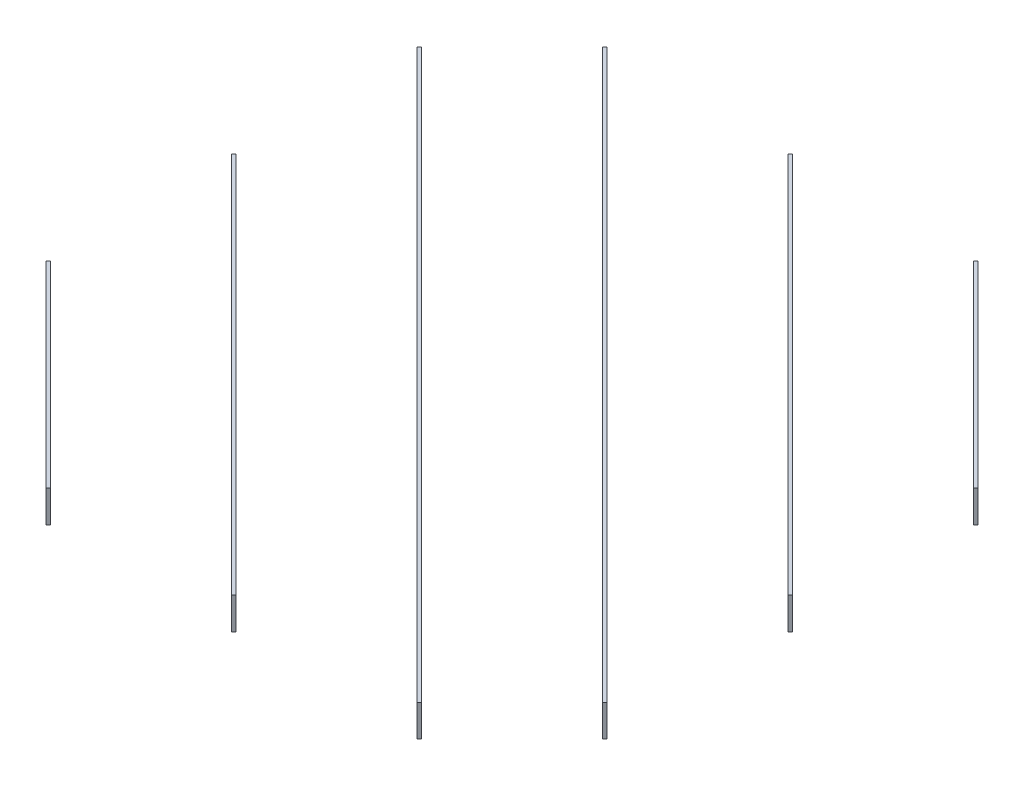
from build123d import *

# Parameters (mm, degrees)
BOSS_EXTRUDE1_DEPTH   = 60
BOSS_EXTRUDE1_2_DEPTH = 60
BOSS_EXTRUDE1_3_DEPTH = 60
BOSS_EXTRUDE1_4_DEPTH = 60
BOSS_EXTRUDE1_5_DEPTH = 60
BOSS_EXTRUDE1_6_DEPTH = 60
SKETCH3_R             = 1.5
SKETCH3_W             = 6
SKETCH3_H             = 60
CUT_EXTRUDE1_DEPTH    = 1506.601910021
SKETCH4_R             = 1.5
CUT_EXTRUDE2_DEPTH    = 1506.601910021


with BuildPart() as part:
    # Sketch2 → Boss-Extrude1 (new body)
    with BuildSketch(Plane(origin=(0, 0, 0), x_dir=(1, 0, 0), z_dir=(0, 1, 0))):
        Polygon((-625, -254.242640687), (-254.242640687, -625), (-250, -620.757359313), (-620.757359313, -250), align=None)
    extrude(amount=BOSS_EXTRUDE1_DEPTH)


with BuildPart() as body_2:
    # Sketch2 → Boss-Extrude1 2 (new body)
    with BuildSketch(Plane(origin=(0, 0, 0), x_dir=(1, 0, 0), z_dir=(0, 1, 0))):
        Polygon((-625, 95.757359313), (95.757359313, -625), (100, -620.757359313), (-620.757359313, 100), align=None)
    extrude(amount=BOSS_EXTRUDE1_2_DEPTH)


with BuildPart() as body_3:
    # Sketch2 → Boss-Extrude1 3 (new body)
    with BuildSketch(Plane(origin=(0, 0, 0), x_dir=(1, 0, 0), z_dir=(0, 1, 0))):
        Polygon((-625, 445.757359313), (445.757359313, -625), (450, -620.757359313), (-620.757359313, 450), align=None)
    extrude(amount=BOSS_EXTRUDE1_3_DEPTH)


with BuildPart() as body_4:
    # Sketch2 → Boss-Extrude1 4 (new body)
    with BuildSketch(Plane(origin=(0, 0, 0), x_dir=(1, 0, 0), z_dir=(0, 1, 0))):
        Polygon((-450, 620.757359313), (620.757359313, -450), (625, -445.757359313), (-445.757359313, 625), align=None)
    extrude(amount=BOSS_EXTRUDE1_4_DEPTH)


with BuildPart() as body_5:
    # Sketch2 → Boss-Extrude1 5 (new body)
    with BuildSketch(Plane(origin=(0, 0, 0), x_dir=(1, 0, 0), z_dir=(0, 1, 0))):
        Polygon((-100, 620.757359313), (620.757359313, -100), (625, -95.757359313), (-95.757359313, 625), align=None)
    extrude(amount=BOSS_EXTRUDE1_5_DEPTH)


with BuildPart() as body_6:
    # Sketch2 → Boss-Extrude1 6 (new body)
    with BuildSketch(Plane(origin=(0, 0, 0), x_dir=(1, 0, 0), z_dir=(0, 1, 0))):
        Polygon((250, 620.757359313), (620.757359313, 250), (625, 254.242640687), (254.242640687, 625), align=None)
    extrude(amount=BOSS_EXTRUDE1_6_DEPTH)


with BuildPart() as cut_extrude1_tool:
    # Sketch3 → Cut-Extrude1 (new body, through all)
    with BuildSketch(Plane(origin=(-439.621320344, 0, 439.621320344), x_dir=(0.707106781, 0, 0.707106781), z_dir=(-0.707106781, 0, 0.707106781))):
        with Locations((-615.718433538, 30)):
            Circle(SKETCH3_R)
        with Locations((-621.718433538, 30)):
            Circle(SKETCH3_R)
        with Locations((-618.718433538, 0)):
            Rectangle(SKETCH3_W, SKETCH3_H)
        with BuildLine():
            Line((-621.718433538, 28.5), (-621.718433538, 30))
            Line((-621.718433538, 30), (-620.218433538, 30))
            ThreePointArc((-620.218433538, 30), (-622.77909371, 31.060660172), (-621.718433538, 28.5))
        make_face()
        with BuildLine():
            Line((-620.218433538, 30), (-621.718433538, 30))
            Line((-621.718433538, 30), (-621.718433538, 28.5))
            ThreePointArc((-621.718433538, 28.5), (-620.657773366, 28.939339828), (-620.218433538, 30))
        make_face()
        with BuildLine():
            ThreePointArc((-614.218433538, 30), (-615.718433538, 31.5), (-617.218433538, 30))
            Line((-617.218433538, 30), (-615.718433538, 30))
            Line((-615.718433538, 30), (-615.718433538, 28.5))
            ThreePointArc((-615.718433538, 28.5), (-614.657773366, 28.939339828), (-614.218433538, 30))
        make_face()
        with BuildLine():
            Line((-615.718433538, 30), (-617.218433538, 30))
            ThreePointArc((-617.218433538, 30), (-616.77909371, 28.939339828), (-615.718433538, 28.5))
            Line((-615.718433538, 28.5), (-615.718433538, 30))
        make_face()
        with BuildLine():
            Line((-374.231060123, 28.5), (-374.231060123, 30))
            Line((-374.231060123, 30), (-372.731060123, 30))
            ThreePointArc((-372.731060123, 30), (-375.291720295, 31.060660172), (-374.231060123, 28.5))
        make_face()
        with BuildLine():
            Line((-372.731060123, 30), (-374.231060123, 30))
            Line((-374.231060123, 30), (-374.231060123, 28.5))
            ThreePointArc((-374.231060123, 28.5), (-373.170399951, 28.939339828), (-372.731060123, 30))
        make_face()
        with Locations((-368.231060123, 30)):
            Circle(SKETCH3_R)
        with Locations((-374.231060123, 30)):
            Circle(SKETCH3_R)
        with Locations((-371.231060123, 0)):
            Rectangle(SKETCH3_W, SKETCH3_H)
        with BuildLine():
            ThreePointArc((-366.731060123, 30), (-368.231060123, 31.5), (-369.731060123, 30))
            Line((-369.731060123, 30), (-368.231060123, 30))
            Line((-368.231060123, 30), (-368.231060123, 28.5))
            ThreePointArc((-368.231060123, 28.5), (-367.170399951, 28.939339828), (-366.731060123, 30))
        make_face()
        with BuildLine():
            Line((-368.231060123, 30), (-369.731060123, 30))
            ThreePointArc((-369.731060123, 30), (-369.291720295, 28.939339828), (-368.231060123, 28.5))
            Line((-368.231060123, 28.5), (-368.231060123, 30))
        make_face()
        with BuildLine():
            Line((-126.705577884, 28.5), (-126.705577884, 30))
            Line((-126.705577884, 30), (-125.205577884, 30))
            ThreePointArc((-125.205577884, 30), (-127.766238056, 31.060660172), (-126.705577884, 28.5))
        make_face()
        with BuildLine():
            Line((-125.205577884, 30), (-126.705577884, 30))
            Line((-126.705577884, 30), (-126.705577884, 28.5))
            ThreePointArc((-126.705577884, 28.5), (-125.644917713, 28.939339828), (-125.205577884, 30))
        make_face()
        with BuildLine():
            ThreePointArc((-119.205577884, 30), (-120.705577884, 31.5), (-122.205577884, 30))
            Line((-122.205577884, 30), (-120.705577884, 30))
            Line((-120.705577884, 30), (-120.705577884, 28.5))
            ThreePointArc((-120.705577884, 28.5), (-119.644917713, 28.939339828), (-119.205577884, 30))
        make_face()
        with BuildLine():
            Line((-120.705577884, 30), (-122.205577884, 30))
            ThreePointArc((-122.205577884, 30), (-121.766238056, 28.939339828), (-120.705577884, 28.5))
            Line((-120.705577884, 28.5), (-120.705577884, 30))
        make_face()
        with BuildLine():
            Line((-122.205577884, 30), (-125.205577884, 30))
            ThreePointArc((-125.205577884, 30), (-125.644917713, 28.939339828), (-126.705577884, 28.5))
            Line((-126.705577884, 28.5), (-126.705577884, 0))
            Line((-126.705577884, 0), (-120.705577884, 0))
            Line((-120.705577884, 0), (-120.705577884, 28.5))
            ThreePointArc((-120.705577884, 28.5), (-121.766238056, 28.939339828), (-122.205577884, 30))
        make_face()
        with BuildLine():
            ThreePointArc((122.205577884, 30), (119.644917713, 31.060660172), (120.705577884, 28.5))
            Line((120.705577884, 28.5), (120.705577884, 30))
            Line((120.705577884, 30), (122.205577884, 30))
        make_face()
        with BuildLine():
            Line((120.705577884, 30), (120.705577884, 28.5))
            ThreePointArc((120.705577884, 28.5), (121.766238056, 28.939339828), (122.205577884, 30))
            Line((122.205577884, 30), (120.705577884, 30))
        make_face()
        with BuildLine():
            Line((120.705577884, 28.5), (120.705577884, 0))
            Line((120.705577884, 0), (126.705577884, 0))
            Line((126.705577884, 0), (126.705577884, 28.5))
            ThreePointArc((126.705577884, 28.5), (125.644917713, 28.939339828), (125.205577884, 30))
            Line((125.205577884, 30), (122.205577884, 30))
            ThreePointArc((122.205577884, 30), (121.766238056, 28.939339828), (120.705577884, 28.5))
        make_face()
        with BuildLine():
            ThreePointArc((125.205577884, 30), (125.644917713, 28.939339828), (126.705577884, 28.5))
            Line((126.705577884, 28.5), (126.705577884, 30))
            Line((126.705577884, 30), (125.205577884, 30))
        make_face()
        with BuildLine():
            Line((126.705577884, 30), (126.705577884, 28.5))
            ThreePointArc((126.705577884, 28.5), (127.766238056, 28.939339828), (128.205577884, 30))
            ThreePointArc((128.205577884, 30), (126.705577884, 31.5), (125.205577884, 30))
            Line((125.205577884, 30), (126.705577884, 30))
        make_face()
        with BuildLine():
            Line((369.731060123, 30), (368.231060123, 30))
            Line((368.231060123, 30), (368.231060123, 28.5))
            ThreePointArc((368.231060123, 28.5), (369.291720295, 28.939339828), (369.731060123, 30))
        make_face()
        with BuildLine():
            Line((368.231060123, 28.5), (368.231060123, 30))
            Line((368.231060123, 30), (369.731060123, 30))
            ThreePointArc((369.731060123, 30), (367.170399951, 31.060660172), (368.231060123, 28.5))
        make_face()
        with Locations((374.231060123, 30)):
            Circle(SKETCH3_R)
        with Locations((368.231060123, 30)):
            Circle(SKETCH3_R)
        with Locations((371.231060123, 0)):
            Rectangle(SKETCH3_W, SKETCH3_H)
        with BuildLine():
            ThreePointArc((375.731060123, 30), (374.231060123, 31.5), (372.731060123, 30))
            Line((372.731060123, 30), (374.231060123, 30))
            Line((374.231060123, 30), (374.231060123, 28.5))
            ThreePointArc((374.231060123, 28.5), (375.291720295, 28.939339828), (375.731060123, 30))
        make_face()
        with BuildLine():
            Line((374.231060123, 30), (372.731060123, 30))
            ThreePointArc((372.731060123, 30), (373.170399951, 28.939339828), (374.231060123, 28.5))
            Line((374.231060123, 28.5), (374.231060123, 30))
        make_face()
        with BuildLine():
            Line((617.218433538, 30), (615.718433538, 30))
            Line((615.718433538, 30), (615.718433538, 28.5))
            ThreePointArc((615.718433538, 28.5), (616.77909371, 28.939339828), (617.218433538, 30))
        make_face()
        with BuildLine():
            Line((615.718433538, 28.5), (615.718433538, 30))
            Line((615.718433538, 30), (617.218433538, 30))
            ThreePointArc((617.218433538, 30), (614.657773366, 31.060660172), (615.718433538, 28.5))
        make_face()
        with BuildLine():
            ThreePointArc((623.218433538, 30), (621.718433538, 31.5), (620.218433538, 30))
            Line((620.218433538, 30), (621.718433538, 30))
            Line((621.718433538, 30), (621.718433538, 28.5))
            ThreePointArc((621.718433538, 28.5), (622.77909371, 28.939339828), (623.218433538, 30))
        make_face()
        with BuildLine():
            Line((621.718433538, 30), (620.218433538, 30))
            ThreePointArc((620.218433538, 30), (620.657773366, 28.939339828), (621.718433538, 28.5))
            Line((621.718433538, 28.5), (621.718433538, 30))
        make_face()
        with Locations((621.718433538, 30)):
            Circle(SKETCH3_R)
        with Locations((615.718433538, 30)):
            Circle(SKETCH3_R)
        with Locations((618.718433538, 0)):
            Rectangle(SKETCH3_W, SKETCH3_H)
    extrude(amount=-CUT_EXTRUDE1_DEPTH)


with BuildPart() as part_1:
    add(part.part)

    # Cut-Extrude1: cut by cut_extrude1_tool
    add(cut_extrude1_tool.part, mode=Mode.SUBTRACT)


with BuildPart() as body_2_1:
    add(body_2.part)

    # Cut-Extrude1: cut by cut_extrude1_tool
    add(cut_extrude1_tool.part, mode=Mode.SUBTRACT)


with BuildPart() as body_3_1:
    add(body_3.part)

    # Cut-Extrude1: cut by cut_extrude1_tool
    add(cut_extrude1_tool.part, mode=Mode.SUBTRACT)


with BuildPart() as body_4_1:
    add(body_4.part)

    # Cut-Extrude1: cut by cut_extrude1_tool
    add(cut_extrude1_tool.part, mode=Mode.SUBTRACT)


with BuildPart() as body_5_1:
    add(body_5.part)

    # Cut-Extrude1: cut by cut_extrude1_tool
    add(cut_extrude1_tool.part, mode=Mode.SUBTRACT)


with BuildPart() as body_6_1:
    add(body_6.part)

    # Cut-Extrude1: cut by cut_extrude1_tool
    add(cut_extrude1_tool.part, mode=Mode.SUBTRACT)


with BuildPart() as cut_extrude2_tool:
    # Sketch4 → Cut-Extrude2 (new body, through all)
    with BuildSketch(Plane(origin=(-439.621320344, 0, 439.621320344), x_dir=(0.707106781, 0, 0.707106781), z_dir=(-0.707106781, 0, 0.707106781))):
        Circle(SKETCH4_R)
    extrude(amount=-CUT_EXTRUDE2_DEPTH)


with BuildPart() as part_2:
    add(part_1.part)

    # Cut-Extrude2: cut by cut_extrude2_tool
    add(cut_extrude2_tool.part, mode=Mode.SUBTRACT)


with BuildPart() as body_2_2:
    add(body_2_1.part)

    # Cut-Extrude2: cut by cut_extrude2_tool
    add(cut_extrude2_tool.part, mode=Mode.SUBTRACT)


with BuildPart() as body_3_2:
    add(body_3_1.part)

    # Cut-Extrude2: cut by cut_extrude2_tool
    add(cut_extrude2_tool.part, mode=Mode.SUBTRACT)


with BuildPart() as body_4_2:
    add(body_4_1.part)

    # Cut-Extrude2: cut by cut_extrude2_tool
    add(cut_extrude2_tool.part, mode=Mode.SUBTRACT)


with BuildPart() as body_5_2:
    add(body_5_1.part)

    # Cut-Extrude2: cut by cut_extrude2_tool
    add(cut_extrude2_tool.part, mode=Mode.SUBTRACT)


with BuildPart() as body_6_2:
    add(body_6_1.part)

    # Cut-Extrude2: cut by cut_extrude2_tool
    add(cut_extrude2_tool.part, mode=Mode.SUBTRACT)


solid = Compound([part_2.part, body_2_2.part, body_3_2.part, body_4_2.part, body_5_2.part, body_6_2.part])
